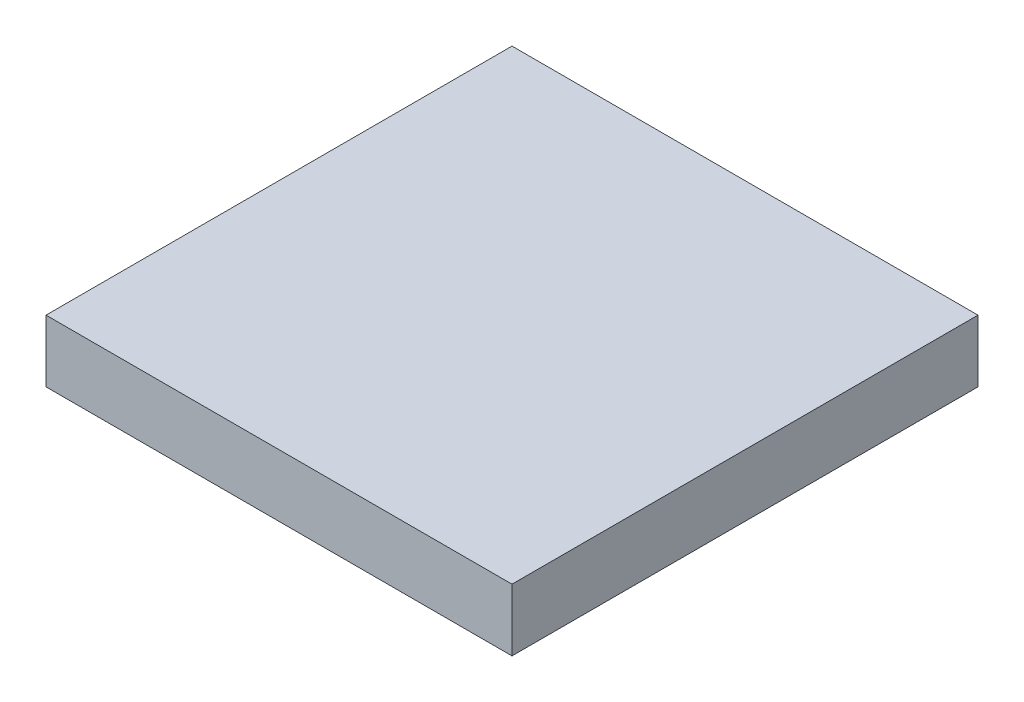
from build123d import *

# Parameters (mm, degrees)
SKETCH1_W           = 75
SKETCH1_H           = 75
BOSS_EXTRUDE1_DEPTH = 10


with BuildPart() as part:
    # Sketch1 → Boss-Extrude1 (new body)
    with BuildSketch(Plane(origin=(0, 0, 0), x_dir=(1, 0, 0), z_dir=(0, 1, 0))):
        with Locations((37.5, 37.5)):
            Rectangle(SKETCH1_W, SKETCH1_H)
    extrude(amount=BOSS_EXTRUDE1_DEPTH)


solid = part.part
